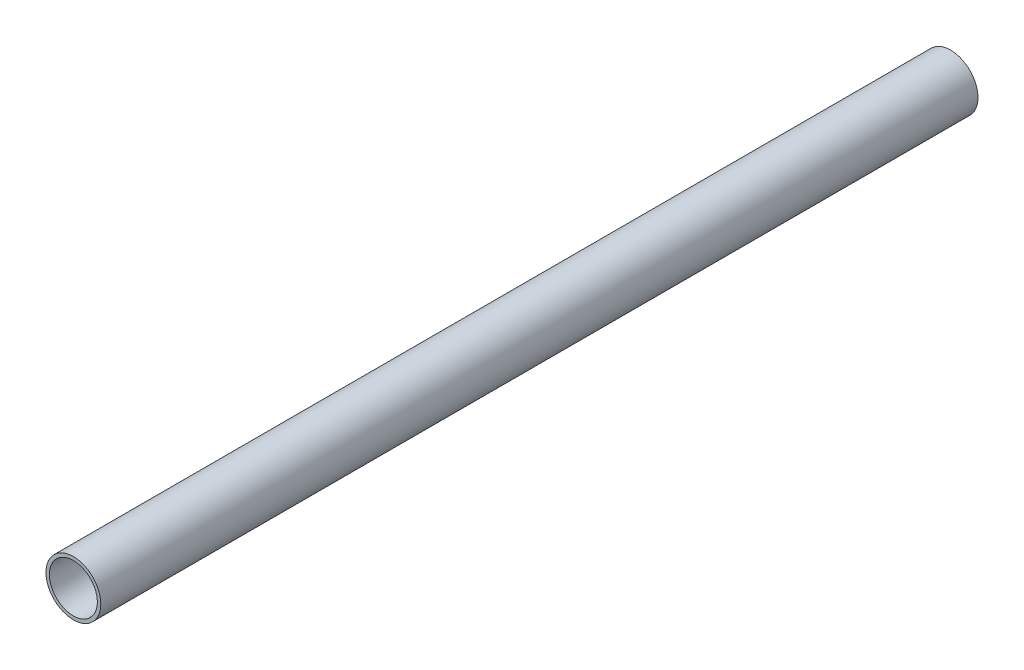
from build123d import *

# Parameters (mm, degrees)
SKETCH1_R           = 12.7
SKETCH1_R_2         = 11.1125
BOSS_EXTRUDE1_DEPTH = 406.4


with BuildPart() as part:
    # Sketch1 → Boss-Extrude1 (new body)
    with BuildSketch(Plane.XY):
        Circle(SKETCH1_R)
        Circle(SKETCH1_R_2, mode=Mode.SUBTRACT)
    extrude(amount=BOSS_EXTRUDE1_DEPTH)


solid = part.part
